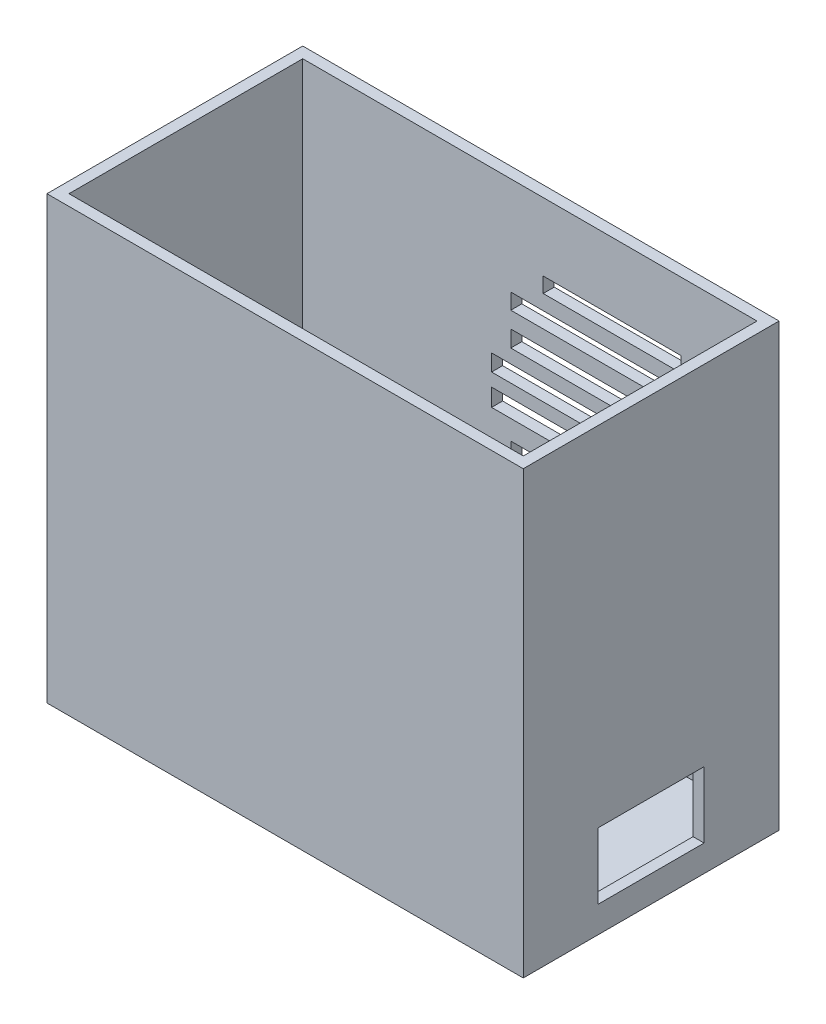
from build123d import *

# Parameters (mm, degrees)
SKETCH1_W           = 54
SKETCH1_H           = 29
BOSS_EXTRUDE1_DEPTH = 50
SHELL1_T            = -1.25
SKETCH2_W           = 35.25
SKETCH2_H           = 21
CUT_EXTRUDE1_DEPTH  = 51
CUT_EXTRUDE2_REACH  = 56
SKETCH3_W           = 12
SKETCH3_H           = 7.5
CUT_EXTRUDE3_REACH  = 52
SKETCH4_W           = 13
SKETCH4_H           = 1.5
CUT_EXTRUDE4_REACH  = 31
SKETCH6_W           = 15.64520267
SKETCH6_H           = 1.830091839
SKETCH6_W_2         = 22.646740458
SKETCH6_H_2         = 2.116515958
SKETCH6_W_3         = 26.646589607
SKETCH6_H_3         = 1.98929613
SKETCH6_H_4         = 1.878154188
SKETCH6_H_5         = 1.86823604
SKETCH6_H_6         = 1.784322078
SKETCH6_H_7         = 1.716719878


with BuildPart() as part:
    # Sketch1 → Boss-Extrude1 (new body)
    with BuildSketch(Plane(origin=(0, 0, 0), x_dir=(1, 0, 0), z_dir=(0, 1, 0))):
        Rectangle(SKETCH1_W, SKETCH1_H)
    extrude(amount=BOSS_EXTRUDE1_DEPTH)

    # Shell1
    shell1_openings = [part.faces().sort_by_distance(p)[0] for p in [
        (0, 50, 0),
    ]]
    offset(amount=SHELL1_T, openings=shell1_openings, kind=Kind.INTERSECTION)

    # Sketch2 → Cut-Extrude1 (cut, through all)
    with BuildSketch(Plane.XZ):
        with Locations((-6.625, 0)):
            Rectangle(SKETCH2_W, SKETCH2_H)
    extrude(amount=-CUT_EXTRUDE1_DEPTH, mode=Mode.SUBTRACT)

    # Sketch3 → Cut-Extrude2 (cut, up to next)
    with BuildSketch(Plane(origin=(27, 0, 0), x_dir=(0, 0, -1), z_dir=(1, 0, 0)), mode=Mode.PRIVATE) as cut_extrude2_sk1:
        with Locations((0, 6.75)):
            Rectangle(SKETCH3_W, SKETCH3_H)
    cut_extrude2_tool1 = extrude(cut_extrude2_sk1.sketch, amount=-CUT_EXTRUDE2_REACH, mode=Mode.PRIVATE) & part.part
    add(cut_extrude2_tool1.solids().sort_by_distance((27, 6.75, 0))[0], mode=Mode.SUBTRACT)

    # Sketch4 → Cut-Extrude3 (cut, up to next)
    with BuildSketch(Plane.XZ, mode=Mode.PRIVATE) as cut_extrude3_sk1:
        with Locations((-6.625, 11.25)):
            Rectangle(SKETCH4_W, SKETCH4_H)
    cut_extrude3_tool1 = extrude(cut_extrude3_sk1.sketch, amount=-CUT_EXTRUDE3_REACH, mode=Mode.PRIVATE) & part.part
    add(cut_extrude3_tool1.solids().sort_by_distance((-6.625, 0, 11.25))[0], mode=Mode.SUBTRACT)

    # Sketch6 → Cut-Extrude4 (cut, up to next)
    with BuildSketch(Plane(origin=(0, 0, -14.5), x_dir=(-1, 0, 0), z_dir=(0, 0, -1)), mode=Mode.PRIVATE) as cut_extrude4_sk1:
        with Locations((-9.330453993, 19.365591302)):
            Rectangle(SKETCH6_W, SKETCH6_H)
    cut_extrude4_tool1 = extrude(cut_extrude4_sk1.sketch, amount=-CUT_EXTRUDE4_REACH, mode=Mode.PRIVATE) & part.part
    add(cut_extrude4_tool1.solids().sort_by_distance((9.330454, 19.365591, -14.5))[0], mode=Mode.SUBTRACT)
    # Sketch6 → Cut-Extrude4 (cut, up to next)
    with BuildSketch(Plane(origin=(0, 0, -14.5), x_dir=(-1, 0, 0), z_dir=(0, 0, -1)), mode=Mode.PRIVATE) as cut_extrude4_sk2:
        with Locations((-9.158424139, 23.200549922)):
            Rectangle(SKETCH6_W_2, SKETCH6_H_2)
    cut_extrude4_tool2 = extrude(cut_extrude4_sk2.sketch, amount=-CUT_EXTRUDE4_REACH, mode=Mode.PRIVATE) & part.part
    add(cut_extrude4_tool2.solids().sort_by_distance((9.158424, 23.20055, -14.5))[0], mode=Mode.SUBTRACT)
    # Sketch6 → Cut-Extrude4 (cut, up to next)
    with BuildSketch(Plane(origin=(0, 0, -14.5), x_dir=(-1, 0, 0), z_dir=(0, 0, -1)), mode=Mode.PRIVATE) as cut_extrude4_sk3:
        with Locations((-8.981382512, 27.470306386)):
            Rectangle(SKETCH6_W_3, SKETCH6_H_3)
    cut_extrude4_tool3 = extrude(cut_extrude4_sk3.sketch, amount=-CUT_EXTRUDE4_REACH, mode=Mode.PRIVATE) & part.part
    add(cut_extrude4_tool3.solids().sort_by_distance((8.981383, 27.470306, -14.5))[0], mode=Mode.SUBTRACT)
    # Sketch6 → Cut-Extrude4 (cut, up to next)
    with BuildSketch(Plane(origin=(0, 0, -14.5), x_dir=(-1, 0, 0), z_dir=(0, 0, -1)), mode=Mode.PRIVATE) as cut_extrude4_sk4:
        with Locations((-8.981382512, 30.885196162)):
            Rectangle(SKETCH6_W_3, SKETCH6_H_4)
    cut_extrude4_tool4 = extrude(cut_extrude4_sk4.sketch, amount=-CUT_EXTRUDE4_REACH, mode=Mode.PRIVATE) & part.part
    add(cut_extrude4_tool4.solids().sort_by_distance((8.981383, 30.885196, -14.5))[0], mode=Mode.SUBTRACT)
    # Sketch6 → Cut-Extrude4 (cut, up to next)
    with BuildSketch(Plane(origin=(0, 0, -14.5), x_dir=(-1, 0, 0), z_dir=(0, 0, -1)), mode=Mode.PRIVATE) as cut_extrude4_sk5:
        with Locations((-9.158424139, 34.324467927)):
            Rectangle(SKETCH6_W_2, SKETCH6_H_5)
    cut_extrude4_tool5 = extrude(cut_extrude4_sk5.sketch, amount=-CUT_EXTRUDE4_REACH, mode=Mode.PRIVATE) & part.part
    add(cut_extrude4_tool5.solids().sort_by_distance((9.158424, 34.324468, -14.5))[0], mode=Mode.SUBTRACT)
    # Sketch6 → Cut-Extrude4 (cut, up to next)
    with BuildSketch(Plane(origin=(0, 0, -14.5), x_dir=(-1, 0, 0), z_dir=(0, 0, -1)), mode=Mode.PRIVATE) as cut_extrude4_sk6:
        with Locations((-9.158424139, 37.995559626)):
            Rectangle(SKETCH6_W_2, SKETCH6_H_6)
    cut_extrude4_tool6 = extrude(cut_extrude4_sk6.sketch, amount=-CUT_EXTRUDE4_REACH, mode=Mode.PRIVATE) & part.part
    add(cut_extrude4_tool6.solids().sort_by_distance((9.158424, 37.99556, -14.5))[0], mode=Mode.SUBTRACT)
    # Sketch6 → Cut-Extrude4 (cut, up to next)
    with BuildSketch(Plane(origin=(0, 0, -14.5), x_dir=(-1, 0, 0), z_dir=(0, 0, -1)), mode=Mode.PRIVATE) as cut_extrude4_sk7:
        with Locations((-9.330453993, 41.439907402)):
            Rectangle(SKETCH6_W, SKETCH6_H_7)
    cut_extrude4_tool7 = extrude(cut_extrude4_sk7.sketch, amount=-CUT_EXTRUDE4_REACH, mode=Mode.PRIVATE) & part.part
    add(cut_extrude4_tool7.solids().sort_by_distance((9.330454, 41.439907, -14.5))[0], mode=Mode.SUBTRACT)


solid = part.part
